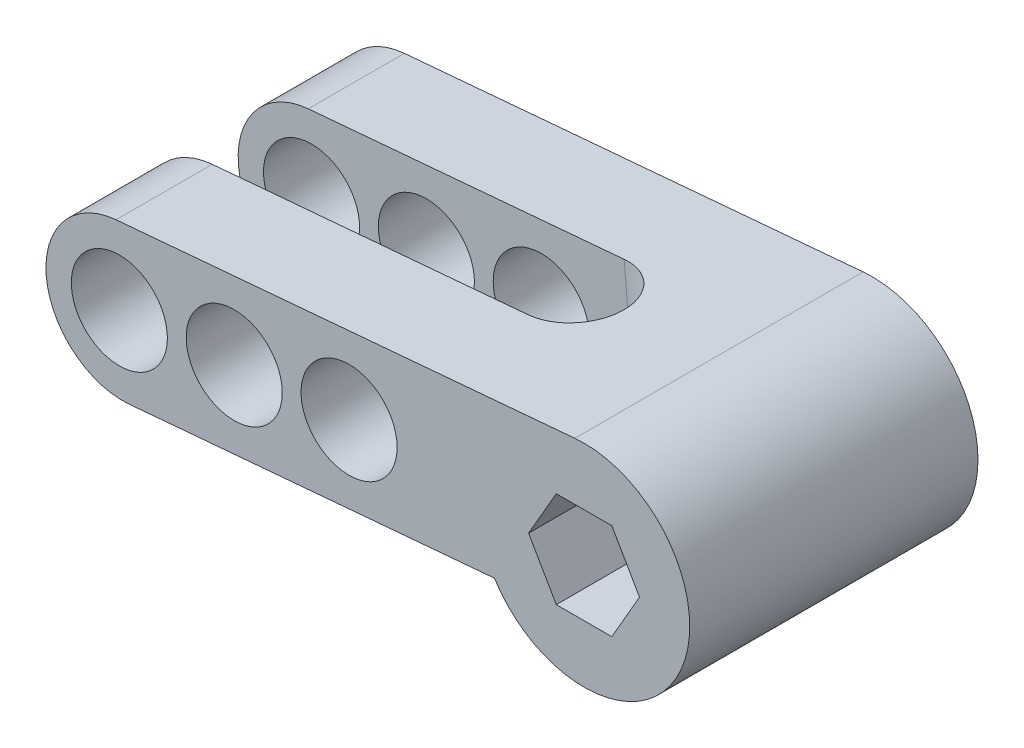
from build123d import *

# Parameters (mm, degrees)
BOSS_EXTRUDE1_DEPTH = 30
CUT_EXTRUDE1_DEPTH  = 23.916854849
SKETCH3_R           = 5
CUT_EXTRUDE2_DEPTH  = 31


with BuildPart() as part:
    # Sketch1 → Boss-Extrude1 (new body)
    with BuildSketch(Plane.XY):
        with BuildLine():
            Line((23.159950064, 11.160474583), (-24.578582707, 6.983894152))
            ThreePointArc((-24.578582707, 6.983894152), (-31.85089435, -1.682909374), (-23.184090823, -8.955221017))
            Line((-23.184090823, -8.955221017), (14.793767169, -5.632588978))
            ThreePointArc((14.793767169, -5.632588978), (33.964469482, -4.702776608), (23.159950064, 11.160474583))
        make_face()
        Polygon((27.005414581, -4.797667096), (29.892165926, 0.202332904), (27.005414581, 5.202332904), (21.231911889, 5.202332904), (18.345160543, 0.202332904), (21.231911889, -4.797667096), align=None, mode=Mode.SUBTRACT)
    extrude(amount=BOSS_EXTRUDE1_DEPTH)

    # Sketch2 → Cut-Extrude1 (cut, through all)
    with BuildSketch(Plane(origin=(-0.793072196, 9.064856678, 0), x_dir=(0.996194698, 0.087155743, 0), z_dir=(-0.087155743, 0.996194698, 0))):
        with BuildLine():
            Line((-32.881194949, -10), (9.118805051, -10))
            ThreePointArc((9.118805051, -10), (14.118805051, -15), (9.118805051, -20))
            Line((9.118805051, -20), (-32.881194949, -20))
            Line((-32.881194949, -20), (-32.881194949, -10))
        make_face()
    extrude(amount=-CUT_EXTRUDE1_DEPTH, mode=Mode.SUBTRACT)

    # Sketch3 → Cut-Extrude2 (cut, through all)
    with BuildSketch(Plane.XY.offset(30)):
        with Locations((-24.243526624, -1.017350939)):
            Circle(SKETCH3_R)
        with Locations((-12.289190247, 0.028517974)):
            Circle(SKETCH3_R)
        with Locations((-0.33485387, 1.074386887)):
            Circle(SKETCH3_R)
    extrude(amount=-CUT_EXTRUDE2_DEPTH, mode=Mode.SUBTRACT)


solid = part.part
